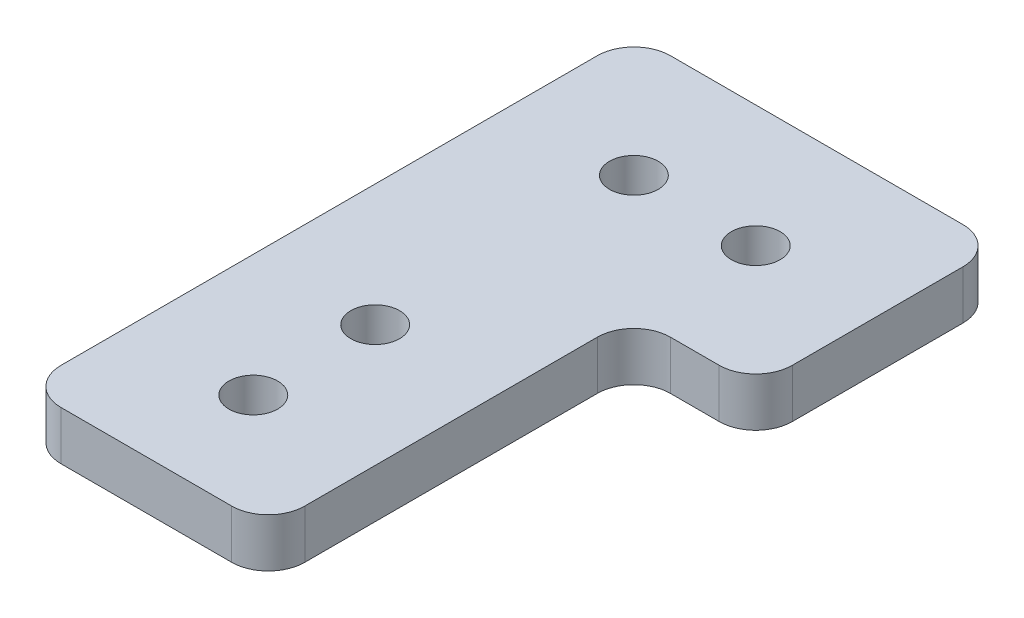
from build123d import *

# Parameters (mm, degrees)
SKETCH1_R           = 2
BOSS_EXTRUDE1_DEPTH = 4
FILLET1_R           = 3


with BuildPart() as part:
    # Sketch1 → Boss-Extrude1 (new body)
    with BuildSketch(Plane(origin=(0, 0, 0), x_dir=(1, 0, 0), z_dir=(0, 1, 0))):
        Polygon((0, 0), (20, 0), (20, 30), (30, 30), (30, 50), (0, 50), align=None)
        with Locations((10, 18.773227759)):
            Circle(SKETCH1_R, mode=Mode.SUBTRACT)
        with Locations((10, 8.773227759)):
            Circle(SKETCH1_R, mode=Mode.SUBTRACT)
        with Locations((20, 40)):
            Circle(SKETCH1_R, mode=Mode.SUBTRACT)
        with Locations((10, 40)):
            Circle(SKETCH1_R, mode=Mode.SUBTRACT)
    extrude(amount=BOSS_EXTRUDE1_DEPTH)

    # Fillet1
    fillet1_edges = [part.edges().sort_by_distance(p)[0] for p in [
        (0, 2, -50),
        (30, 2, -50),
        (30, 2, -30),
        (20, 2, -30),
        (20, 2, 0),
        (0, 2, 0),
    ]]
    fillet(fillet1_edges, radius=FILLET1_R)


solid = part.part
